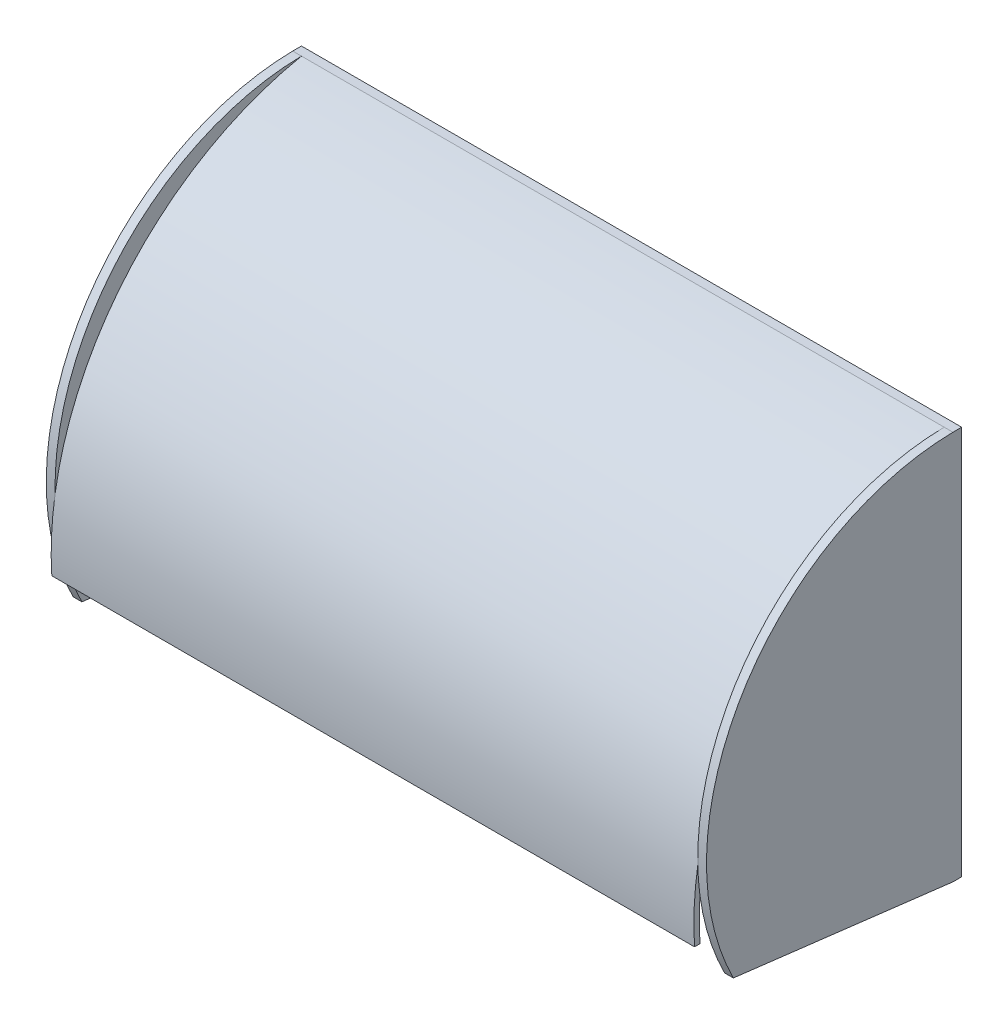
from build123d import *

# Parameters (mm, degrees)
SKETCH1_W           = 186.603203036
SKETCH1_H           = 113.057286536
BOSS_EXTRUDE1_DEPTH = 2.54
BOSS_EXTRUDE2_DEPTH = 186.603203
BOSS_EXTRUDE3_DEPTH = 2.54


with BuildPart() as part:
    # Sketch1 → Boss-Extrude1 (new body)
    with BuildSketch(Plane.XY):
        Rectangle(SKETCH1_W, SKETCH1_H)
    extrude(amount=BOSS_EXTRUDE1_DEPTH)

    # Sketch2 → Boss-Extrude2 (add)
    with BuildSketch(Plane.ZY.offset(93.301601518)):
        with BuildLine():
            Line((2.54, 56.528643268), (2.54, 55.310857912))
            ThreePointArc((2.54, 55.310857912), (55.518181309, 22.042232547), (73.424493654, -37.898180421))
            Line((73.424493654, -37.898180421), (75.017810549, -37.898180421))
            ThreePointArc((75.017810549, -37.898180421), (56.529746856, 22.939984252), (2.54, 56.528643268))
        make_face()
    extrude(amount=-BOSS_EXTRUDE2_DEPTH)

    # Sketch3 → Boss-Extrude3 (add)
    with BuildSketch(Plane.ZY.offset(93.301601518)):
        with BuildLine():
            Line((2.54, 56.528643268), (0, 56.528643268))
            Line((0, 56.528643268), (0, -56.528643268))
            Line((0, -56.528643268), (2.54, -56.528643268))
            Line((2.54, -56.528643268), (66.282828168, -48.823781984))
            ThreePointArc((66.282828168, -48.823781984), (63.598341423, 21.511799087), (2.54, 56.528643268))
        make_face()
    boss_extrude3 = extrude(amount=BOSS_EXTRUDE3_DEPTH)

    # Mirror1: Boss-Extrude3 across plane
    add(boss_extrude3.mirror(Plane(origin=(0, 0, 0), x_dir=(0, 0, 1), z_dir=(1, 0, 0))))


solid = part.part
